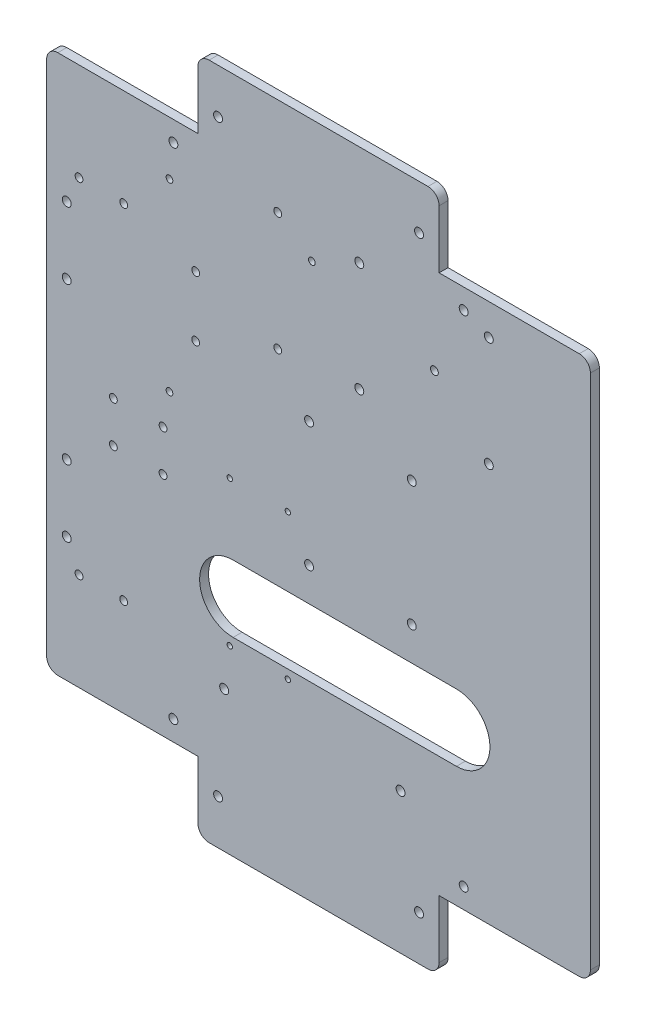
from build123d import *

# Parameters (mm, degrees)
BASE_DEPTH                       = 4
CONG_1_R                         = 3
ENL_V_MAT_EXTRU_1_DEPTH          = 5
ESQUISSE33_R                     = 1.75
PERCAGE_MAIN_DE_DIEU_DEPTH       = 5
ESQUISSE26_R                     = 2
PERCAGE_BUCK_CONVERTER_DEPTH     = 5
ESQUISSE27_R                     = 2
PERCAGE_TEENSY_MOTEUR_DEPTH      = 5
ESQUISSE28_R                     = 1.5
PERCAGE_CARTE_ALIM_DEPTH         = 5
ESQUISSE29_R                     = 2
PERCAGE_RASP_DEPTH               = 5
ESQUISSE32_R                     = 1.75
PERCAGE_TEENSY_ACTIONNEURS_DEPTH = 5
ESQUISSE30_R                     = 2
PERCAGE_ALIM_ACTIONNEURS_DEPTH   = 5
PER_AGE_FILS_DEPTH               = 5
ESQUISSE34_R                     = 1.75
PER_AGE_MOTEUR_ASCENSEUR_DEPTH   = 5
ESQUISSE35_R                     = 1.2
PER_AGE_DRIVER_ASCENSEUR_DEPTH   = 5
ESQUISSE36_R                     = 1.75
ENL_V_MAT_EXTRU_2_DEPTH          = 5
ESQUISSE39_R                     = 2
PER_AGE_EQUERRE_DEPTH            = 5
ESQUISSE38_W                     = 67.748737342
ESQUISSE38_H                     = 31
ENL_V_MAT_EXTRU_3_DEPTH          = 5
CONG_2_R                         = 5


with BuildPart() as part:
    # Esquisse1 → Base (new body)
    with BuildSketch(Plane.XY):
        Polygon((0, 0), (-200, 0), (-224.748737342, 24.748737342), (-224.748737342, 284.748737342), (-200, 309.497474683), (0, 309.497474683), (24.748737342, 284.748737342), (24.748737342, 24.748737342), align=None)
    extrude(amount=BASE_DEPTH)

    # Congé1
    cong_1_edges = [part.edges().sort_by_distance(p)[0] for p in [
        (0, 0, 2),
        (-200, 0, 2),
        (-224.748737342, 24.748737342, 2),
        (-224.748737342, 284.748737342, 2),
        (-200, 309.497474683, 2),
        (0, 309.497474683, 2),
        (24.748737342, 284.748737342, 2),
        (24.748737342, 24.748737342, 2),
    ]]
    fillet(cong_1_edges, radius=CONG_1_R)

    # Esquisse25 → Enlèv. mat.-Extru.1 (cut, through all)
    with BuildSketch(Plane(origin=(0, 0, 0), x_dir=(-1, 0, 0), z_dir=(0, 0, -1))):
        Polygon((-24.748737342, 33), (-24.748737342, 0), (45, 0), (155, 0), (224.748737342, 0), (224.748737342, 33), (224.748737342, 276.497474683), (224.748737342, 309.497474683), (155, 309.497474683), (45, 309.497474683), (-24.748737342, 309.497474683), (-24.748737342, 276.497474683), align=None)
        Polygon((-21.748737342, 33), (45, 33), (45, 3), (155, 3), (155, 33), (221.748737342, 33), (221.748737342, 276.497474683), (155, 276.497474683), (155, 306.497474683), (45, 306.497474683), (45, 276.497474683), (-21.748737342, 276.497474683), align=None, mode=Mode.SUBTRACT)
    extrude(amount=-ENL_V_MAT_EXTRU_1_DEPTH, mode=Mode.SUBTRACT)

    # Esquisse33 → Percage Main_De_Dieu (cut, through all)
    with BuildSketch(Plane.XY.offset(4)):
        with Locations((-207.248737342, 231.748737342)):
            Circle(ESQUISSE33_R)
        with Locations((-187.248737342, 231.748737342)):
            Circle(ESQUISSE33_R)
        with Locations((-207.248737342, 77.748737342)):
            Circle(ESQUISSE33_R)
        with Locations((-187.248737342, 77.748737342)):
            Circle(ESQUISSE33_R)
    extrude(amount=-PERCAGE_MAIN_DE_DIEU_DEPTH, mode=Mode.SUBTRACT)

    # Esquisse26 → Percage Buck Converter (cut, through all)
    with BuildSketch(Plane(origin=(0, 0, 0), x_dir=(-1, 0, 0), z_dir=(0, 0, -1))):
        with Locations((212.748737342, 189.748737342)):
            Circle(ESQUISSE26_R)
        with Locations((212.748737342, 219.748737342)):
            Circle(ESQUISSE26_R)
        with Locations((212.748737342, 89.748737342)):
            Circle(ESQUISSE26_R)
        with Locations((212.748737342, 119.748737342)):
            Circle(ESQUISSE26_R)
    extrude(amount=-PERCAGE_BUCK_CONVERTER_DEPTH, mode=Mode.SUBTRACT)

    # Esquisse27 → Percage Teensy Moteur (cut, through all)
    with BuildSketch(Plane(origin=(0, 0, 0), x_dir=(-1, 0, 0), z_dir=(0, 0, -1))):
        with Locations((142.251262658, 66)):
            Circle(ESQUISSE27_R)
        with Locations((63.251262658, 66)):
            Circle(ESQUISSE27_R)
    extrude(amount=-PERCAGE_TEENSY_MOTEUR_DEPTH, mode=Mode.SUBTRACT)

    # Esquisse28 → Percage Carte Alim (cut, through all)
    with BuildSketch(Plane(origin=(0, 0, 0), x_dir=(-1, 0, 0), z_dir=(0, 0, -1))):
        with Locations((166.748737342, 251.497474683)):
            Circle(ESQUISSE28_R)
        with Locations((102.998737342, 251.497474683)):
            Circle(ESQUISSE28_R)
        with Locations((166.748737342, 169.022474683)):
            Circle(ESQUISSE28_R)
    extrude(amount=-PERCAGE_CARTE_ALIM_DEPTH, mode=Mode.SUBTRACT)

    # Esquisse29 → Percage Rasp (cut, through all)
    with BuildSketch(Plane(origin=(0, 0, 0), x_dir=(-1, 0, 0), z_dir=(0, 0, -1))):
        with Locations((81.748737342, 212.497474683)):
            Circle(ESQUISSE29_R)
        with Locations((23.748737342, 212.497474683)):
            Circle(ESQUISSE29_R)
        with Locations((23.748737342, 261.497474683)):
            Circle(ESQUISSE29_R)
        with Locations((81.748737342, 261.497474683)):
            Circle(ESQUISSE29_R)
    extrude(amount=-PERCAGE_RASP_DEPTH, mode=Mode.SUBTRACT)

    # Esquisse32 → Percage Teensy Actionneurs (cut, through all)
    with BuildSketch(Plane.XY.offset(4)):
        with Locations((-118.251262658, 262.827474683)):
            Circle(ESQUISSE32_R)
        with Locations((-118.251262658, 209.827474683)):
            Circle(ESQUISSE32_R)
        with Locations((-48.111262658, 236.497474683)):
            Circle(ESQUISSE32_R)
    extrude(amount=-PERCAGE_TEENSY_ACTIONNEURS_DEPTH, mode=Mode.SUBTRACT)

    # Esquisse30 → Percage Alim Actionneurs (cut, through all)
    with BuildSketch(Plane(origin=(0, 0, 0), x_dir=(-1, 0, 0), z_dir=(0, 0, -1))):
        with Locations((104.251262658, 133)):
            Circle(ESQUISSE30_R)
        with Locations((58.251262658, 133)):
            Circle(ESQUISSE30_R)
        with Locations((58.251262658, 188.8)):
            Circle(ESQUISSE30_R)
        with Locations((104.251262658, 188.8)):
            Circle(ESQUISSE30_R)
    extrude(amount=-PERCAGE_ALIM_ACTIONNEURS_DEPTH, mode=Mode.SUBTRACT)

    # Esquisse31 → Perçage Fils (cut, through all)
    with BuildSketch(Plane(origin=(0, 0, 0), x_dir=(-1, 0, 0), z_dir=(0, 0, -1))):
        with BuildLine():
            Line((138.251262658, 88), (38.251262658, 88))
            ThreePointArc((38.251262658, 88), (23.251262658, 103), (38.251262658, 118))
            Line((38.251262658, 118), (138.251262658, 118))
            ThreePointArc((138.251262658, 118), (153.251262658, 103), (138.251262658, 88))
        make_face()
    extrude(amount=-PER_AGE_FILS_DEPTH, mode=Mode.SUBTRACT)

    # Esquisse34 → Perçage Moteur Ascenseur (cut, through all)
    with BuildSketch(Plane(origin=(0, 0, 0), x_dir=(-1, 0, 0), z_dir=(0, 0, -1))):
        with Locations((169.623737342, 153.9)):
            Circle(ESQUISSE34_R)
        with Locations((191.873737342, 153.9)):
            Circle(ESQUISSE34_R)
        with Locations((169.623737342, 135.5)):
            Circle(ESQUISSE34_R)
        with Locations((191.873737342, 135.5)):
            Circle(ESQUISSE34_R)
    extrude(amount=-PER_AGE_MOTEUR_ASCENSEUR_DEPTH, mode=Mode.SUBTRACT)

    # Esquisse35 → Perçage Driver Ascenseur (cut, through all)
    with BuildSketch(Plane.XY.offset(4)):
        with Locations((-139.748737342, 149)):
            Circle(ESQUISSE35_R)
        with Locations((-113.748737342, 149)):
            Circle(ESQUISSE35_R)
        with Locations((-113.748737342, 84)):
            Circle(ESQUISSE35_R)
        with Locations((-139.748737342, 84)):
            Circle(ESQUISSE35_R)
    extrude(amount=-PER_AGE_DRIVER_ASCENSEUR_DEPTH, mode=Mode.SUBTRACT)

    # Esquisse36 → Enlèv. mat.-Extru.2 (cut)
    with BuildSketch(Plane.XY.offset(4)):
        with Locations((-155, 194.497474683)):
            Circle(ESQUISSE36_R)
        with Locations((-155, 221.497474683)):
            Circle(ESQUISSE36_R)
    extrude(amount=-ENL_V_MAT_EXTRU_2_DEPTH, mode=Mode.SUBTRACT)

    # Esquisse39 → Perçage Equerre (cut, through all)
    with BuildSketch(Plane.XY.offset(4)):
        with Locations((-145, 286.497474683)):
            Circle(ESQUISSE39_R)
        with Locations((-165, 266.497474683)):
            Circle(ESQUISSE39_R)
        with Locations((-35, 266.497474683)):
            Circle(ESQUISSE39_R)
        with Locations((-55, 286.497474683)):
            Circle(ESQUISSE39_R)
        with Locations((-35, 43)):
            Circle(ESQUISSE39_R)
        with Locations((-55, 23)):
            Circle(ESQUISSE39_R)
        with Locations((-165, 43)):
            Circle(ESQUISSE39_R)
        with Locations((-145, 23)):
            Circle(ESQUISSE39_R)
    extrude(amount=-PER_AGE_EQUERRE_DEPTH, mode=Mode.SUBTRACT)

    # Esquisse38 → Enlèv. mat.-Extru.3 (cut, through all)
    with BuildSketch(Plane(origin=(0, 0, 0), x_dir=(-1, 0, 0), z_dir=(0, 0, -1))):
        with Locations((12.125631329, 18.5)):
            Rectangle(ESQUISSE38_W, ESQUISSE38_H)
        with Locations((187.874368671, 18.5)):
            Rectangle(ESQUISSE38_W, ESQUISSE38_H)
        with Locations((187.874368671, 290.997474683)):
            Rectangle(ESQUISSE38_W, ESQUISSE38_H)
        with Locations((12.125631329, 290.997474683)):
            Rectangle(ESQUISSE38_W, ESQUISSE38_H)
    extrude(amount=-ENL_V_MAT_EXTRU_3_DEPTH, mode=Mode.SUBTRACT)

    # Congé2
    cong_2_edges = [part.edges().sort_by_distance(p)[0] for p in [
        (21.748737342, 275.497474683, 2),
        (-46, 306.497474683, 2),
        (-221.748737342, 275.497474683, 2),
        (-154, 306.497474683, 2),
        (-221.748737342, 34, 2),
        (-154, 3, 2),
        (21.748737342, 34, 2),
        (-46, 3, 2),
    ]]
    fillet(cong_2_edges, radius=CONG_2_R)


solid = part.part
